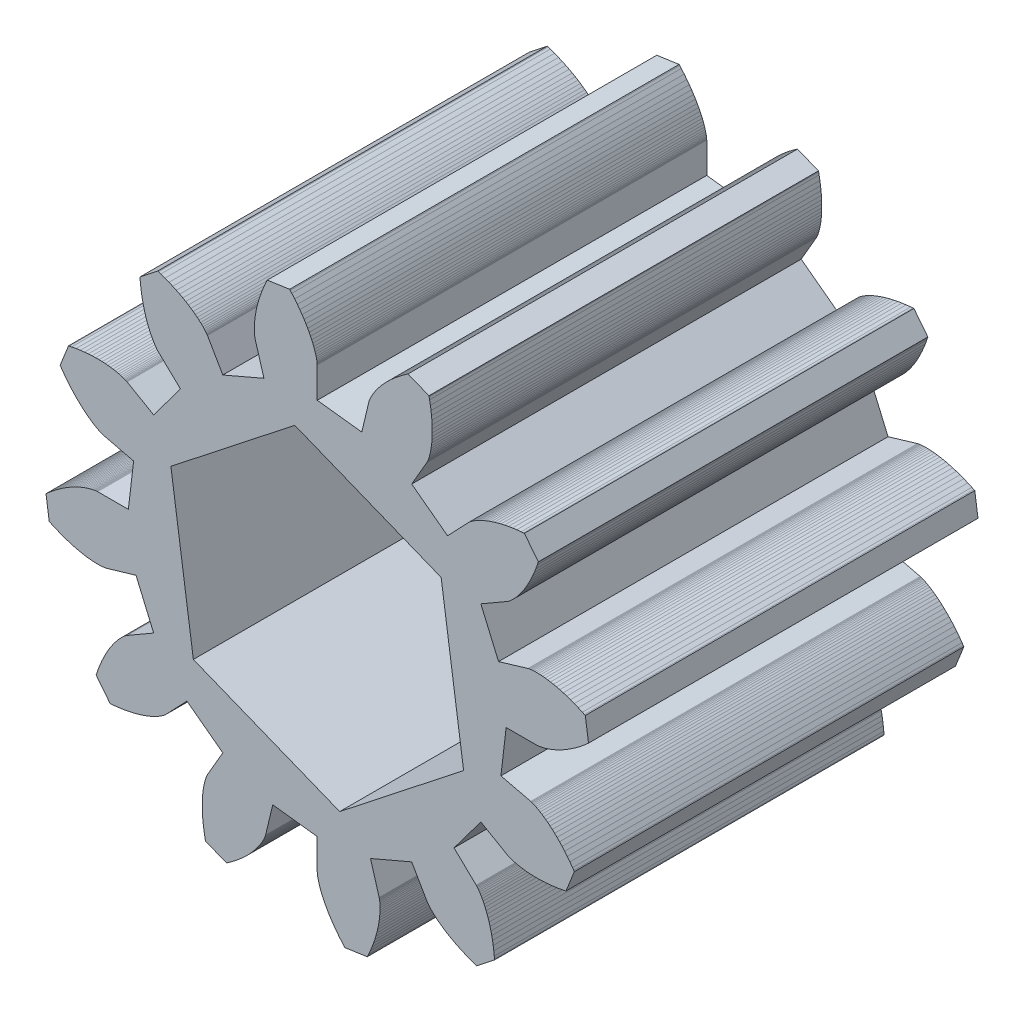
from build123d import *

# Parameters (mm, degrees)
EXTRUDE_2_DEPTH     = 5
CUT_EXTRUDE_1_DEPTH = 6


with BuildPart() as part:
    # Model → ﾎﾞｽ - 押し出し2 (new body)
    with BuildSketch(Plane.XY):
        Polygon((2.424979598, -4.222e-06), (2.819487016, -4.222e-06), (2.822108978, 8.7462e-05), (2.827108083, 0.000398469), (2.834472458, 0.001070503), (2.844181611, 0.002239522), (2.856212048, 0.004043437), (2.870533294, 0.006617481), (2.887107785, 0.010096584), (2.905893622, 0.014612545), (2.926841938, 0.02029636), (2.949899862, 0.027278337), (2.975007008, 0.03568572), (3.002097159, 0.045641409), (3.031101988, 0.057267741), (3.061942483, 0.070684521), (3.094539041, 0.086006313), (3.128804417, 0.103346504), (3.164641474, 0.122811276), (3.201971713, 0.144515903), (3.240674945, 0.168550426), (3.28065269, 0.195017919), (3.321792758, 0.224010967), (3.36398147, 0.255617752), (3.407100449, 0.289922735), (3.451033569, 0.32701359), (3.473258892, 0.346619993), (3.478840026, 0.351634113), (3.481641457, 0.354150934), (3.440698379, 0.641540019), (3.436883916, 0.643384276), (3.430129287, 0.646650076), (3.40330849, 0.659260423), (3.350757413, 0.682589263), (3.299767283, 0.703471908), (3.250424462, 0.722023522), (3.202819232, 0.738358883), (3.157035875, 0.752593787), (3.113156689, 0.764850032), (3.071246876, 0.775252205), (3.031397088, 0.783922058), (2.993650247, 0.790991304), (2.958069816, 0.796588254), (2.924708123, 0.800847778), (2.893609492, 0.80390177), (2.864816257, 0.805887125), (2.838359748, 0.806938769), (2.814269306, 0.807196629), (2.792567266, 0.806797652), (2.773267971, 0.805881803), (2.75638176, 0.804588056), (2.741911972, 0.803055405), (2.729856949, 0.801423854), (2.720208032, 0.799832424), (2.712949555, 0.798418155), (2.708062855, 0.797319091), (2.705520267, 0.796672301), (2.327446991, 0.683992664), (2.100105416, 1.21248071), (2.441756143, 1.409739129), (2.443981931, 1.411127997), (2.448155777, 1.413896895), (2.454197677, 1.418160824), (2.462021578, 1.42402775), (2.471538133, 1.431605395), (2.482653848, 1.440994999), (2.495268621, 1.452294796), (2.509279565, 1.465598744), (2.524579242, 1.480995418), (2.541056364, 1.498571548), (2.558596535, 1.518405742), (2.577079478, 1.540572673), (2.596384821, 1.565144109), (2.616385808, 1.592183092), (2.636953678, 1.621750906), (2.657958434, 1.653900532), (2.679262013, 1.688675948), (2.700738877, 1.726137687), (2.72223945, 1.76630389), (2.743627606, 1.809214204), (2.764759479, 1.854892929), (2.785492363, 1.903359658), (2.805681612, 1.954628288), (2.825184179, 2.008716183), (2.834628019, 2.036808707), (2.836954933, 2.043941444), (2.838112173, 2.047525185), (2.658959587, 2.275939939), (2.654734375, 2.275625296), (2.647254103, 2.275045642), (2.617726989, 2.272491125), (2.560565917, 2.266289323), (2.505982803, 2.258755277), (2.453994401, 2.250032755), (2.404621463, 2.240264695), (2.357878497, 2.229594955), (2.313775498, 2.218170248), (2.272306448, 2.2061305), (2.233489186, 2.193624814), (2.197293861, 2.180791394), (2.163710692, 2.167773573), (2.132718409, 2.154711243), (2.104288575, 2.141742192), (2.078388998, 2.129006261), (2.054978926, 2.11663608), (2.034013762, 2.104766886), (2.015444025, 2.093528445), (1.99921222, 2.083048459), (1.985256909, 2.073453293), (1.973511305, 2.064864663), (1.963903981, 2.057402435), (1.956357685, 2.051182494), (1.950789471, 2.046316218), (1.947114224, 2.042913229), (1.945240347, 2.041077017), (1.67299881, 1.755558806), (1.212332587, 2.100189676), (1.40975052, 2.441748255), (1.410984204, 2.444063663), (1.41321379, 2.44854883), (1.41631411, 2.455262523), (1.420156095, 2.464255487), (1.424608963, 2.475576153), (1.4295402, 2.489265809), (1.43481527, 2.505359023), (1.440297266, 2.523886012), (1.445847995, 2.544869985), (1.451331127, 2.568329549), (1.456603172, 2.594276772), (1.461527082, 2.622715252), (1.465960249, 2.653647415), (1.469762128, 2.687064354), (1.472791158, 2.722954714), (1.474906148, 2.761299531), (1.475967971, 2.802067711), (1.475836949, 2.845248962), (1.474373973, 2.890784204), (1.471440944, 2.938639669), (1.466902951, 2.988764599), (1.460624965, 3.041104481), (1.452474885, 3.095599017), (1.442320147, 3.1521917), (1.436453168, 3.181242596), (1.434901286, 3.18858304), (1.434112004, 3.192265355), (1.164754238, 3.300502144), (1.161252634, 3.298116733), (1.155052015, 3.29389266), (1.130734162, 3.276951053), (1.084283195, 3.243066571), (1.040731658, 3.209312432), (1.000022024, 3.175822105), (0.962100784, 3.142730089), (0.926907907, 3.110169228), (0.89438123, 3.078269169), (0.864443041, 3.047150968), (0.83703557, 3.016951588), (0.812064952, 2.987775117), (0.789450153, 2.959741855), (0.769102961, 2.932962426), (0.750929765, 2.907542224), (0.734834398, 2.883585362), (0.720713262, 2.861187899), (0.708462699, 2.840443271), (0.697972501, 2.821440812), (0.689130672, 2.804261649), (0.681821177, 2.788984569), (0.67592442, 2.775682236), (0.671319309, 2.764422642), (0.66788082, 2.755267805), (0.665481629, 2.74827284), (0.6639939, 2.743490117), (0.663284819, 2.740964192), (0.571318182, 2.357326029), (-2.274e-06, 2.424977651), (-2.274e-06, 2.819485069), (-9.3958e-05, 2.822107031), (-0.000404965, 2.827106136), (-0.001076999, 2.834470511), (-0.002246017, 2.844179664), (-0.004049933, 2.8562101), (-0.006623977, 2.870531346), (-0.01010308, 2.887105837), (-0.014619041, 2.905891674), (-0.020302856, 2.926839991), (-0.027284833, 2.949897915), (-0.035692216, 2.97500506), (-0.045647904, 3.002095212), (-0.057274237, 3.031100041), (-0.070691017, 3.061940535), (-0.086012809, 3.094537093), (-0.103353, 3.12880247), (-0.122817771, 3.164639527), (-0.144522399, 3.201969766), (-0.168556922, 3.240672998), (-0.195024415, 3.280650743), (-0.224017463, 3.32179081), (-0.255624248, 3.363979523), (-0.289929231, 3.407098502), (-0.327020086, 3.451031621), (-0.346626488, 3.473256944), (-0.351640609, 3.478838078), (-0.35415743, 3.48163951), (-0.641546515, 3.440696432), (-0.643390772, 3.436881969), (-0.646656571, 3.430127339), (-0.659277311, 3.403311431), (-0.682626512, 3.350769397), (-0.703528914, 3.299787363), (-0.722099645, 3.250451734), (-0.738453452, 3.202852837), (-0.752706095, 3.157075), (-0.764979342, 3.113200566), (-0.775397753, 3.071294787), (-0.784083047, 3.031448361), (-0.79116692, 2.993704263), (-0.796777656, 2.958126003), (-0.801050107, 2.924765964), (-0.804116149, 2.893668518), (-0.806112661, 2.864876055), (-0.807174556, 2.838419955), (-0.807441751, 2.814329614), (-0.807051183, 2.792627422), (-0.806142812, 2.773327773), (-0.804855609, 2.756441062), (-0.803328565, 2.741970681), (-0.801701685, 2.729915027), (-0.800113995, 2.720265494), (-0.798702537, 2.71300647), (-0.797605367, 2.708119344), (-0.796959563, 2.705576506), (-0.684053296, 2.327570848), (-1.212487206, 2.100103469), (-1.409745625, 2.441754195), (-1.411134493, 2.443979984), (-1.413903391, 2.448153829), (-1.41816732, 2.454195729), (-1.424034246, 2.46201963), (-1.431611891, 2.471536185), (-1.441001495, 2.4826519), (-1.452301292, 2.495266673), (-1.465605239, 2.509277618), (-1.481001914, 2.524577295), (-1.498578044, 2.541054416), (-1.518412238, 2.558594588), (-1.540579169, 2.57707753), (-1.565150605, 2.596382873), (-1.592189588, 2.61638386), (-1.621757402, 2.636951731), (-1.653907028, 2.657956487), (-1.688682443, 2.679260065), (-1.726144183, 2.700736929), (-1.766310386, 2.722237502), (-1.809220699, 2.743625659), (-1.854899425, 2.764757532), (-1.903366154, 2.785490416), (-1.954634784, 2.805679664), (-2.008722679, 2.825182232), (-2.036815203, 2.834626072), (-2.04394794, 2.836952986), (-2.047531681, 2.838110225), (-2.27591146, 2.658487982), (-2.275631791, 2.654732428), (-2.275052138, 2.647252155), (-2.272497621, 2.617725042), (-2.266295819, 2.56056397), (-2.258761773, 2.505980855), (-2.250039251, 2.453992454), (-2.240271191, 2.404619516), (-2.22960145, 2.35787655), (-2.218176744, 2.31377355), (-2.206136996, 2.2723045), (-2.19363131, 2.233487239), (-2.18079789, 2.197291914), (-2.167780069, 2.163708744), (-2.154717739, 2.132716461), (-2.141748688, 2.104286628), (-2.129012757, 2.078387051), (-2.116642576, 2.054976979), (-2.104773381, 2.034011815), (-2.09353494, 2.015442077), (-2.083054955, 1.999210273), (-2.073459788, 1.985254962), (-2.064871159, 1.973509357), (-2.05740893, 1.963902034), (-2.05118899, 1.956355738), (-2.046322713, 1.950787524), (-2.042919725, 1.947112276), (-2.041083513, 1.945238399), (-1.755565302, 1.672996863), (-2.100196172, 1.21233064), (-2.441754751, 1.409748572), (-2.444070159, 1.410982257), (-2.448555326, 1.413211843), (-2.455269018, 1.416312162), (-2.464261983, 1.420154147), (-2.475582649, 1.424607016), (-2.489272305, 1.429538252), (-2.505365519, 1.434813322), (-2.523892507, 1.440295319), (-2.54487648, 1.445846047), (-2.568336044, 1.451329179), (-2.594283268, 1.456601224), (-2.622721748, 1.461525134), (-2.653653911, 1.465958301), (-2.68707085, 1.46976018), (-2.722961209, 1.472789211), (-2.761306027, 1.474904201), (-2.802074207, 1.475966023), (-2.845255458, 1.475835001), (-2.890790699, 1.474372025), (-2.938646165, 1.471438997), (-2.988771095, 1.466901003), (-3.041110977, 1.460623017), (-3.095605512, 1.452472937), (-3.152198196, 1.4423182), (-3.181249092, 1.436451221), (-3.188589536, 1.434899338), (-3.192271851, 1.434110057), (-3.30050864, 1.16475229), (-3.298123228, 1.161250686), (-3.293899156, 1.155050067), (-3.276957549, 1.130732215), (-3.243073067, 1.084281247), (-3.209318928, 1.040729711), (-3.175828601, 1.000020076), (-3.142736585, 0.962098836), (-3.110175724, 0.92690596), (-3.078275665, 0.894379283), (-3.047157463, 0.864441094), (-3.016958084, 0.837033623), (-2.987781613, 0.812063005), (-2.959748351, 0.789448206), (-2.932968922, 0.769101013), (-2.90754872, 0.750927817), (-2.883591858, 0.734832451), (-2.861194395, 0.720711314), (-2.840449767, 0.708460751), (-2.821447308, 0.697970554), (-2.804268145, 0.689128725), (-2.788991064, 0.681819229), (-2.775688732, 0.675922472), (-2.764429138, 0.671317361), (-2.7552743, 0.667878872), (-2.748279336, 0.665479681), (-2.743496613, 0.663991952), (-2.740970688, 0.663282871), (-2.357332525, 0.571316235), (-2.424984147, -4.222e-06), (-2.819491565, -4.222e-06), (-2.822113527, -9.5906e-05), (-2.827112632, -0.000406912), (-2.834477007, -0.001078947), (-2.844186159, -0.002247965), (-2.856216596, -0.00405188), (-2.870537842, -0.006625925), (-2.887112333, -0.010105028), (-2.90589817, -0.014620989), (-2.926846486, -0.020304803), (-2.949904411, -0.02728678), (-2.975011556, -0.035694164), (-3.002101708, -0.045649852), (-3.031106537, -0.057276184), (-3.061947031, -0.070692964), (-3.094543589, -0.086014757), (-3.128808966, -0.103354947), (-3.164646022, -0.122819719), (-3.201976262, -0.144524347), (-3.240679494, -0.16855887), (-3.280657238, -0.195026363), (-3.321797306, -0.22401941), (-3.363986019, -0.255626195), (-3.407104998, -0.289931178), (-3.451038117, -0.327022033), (-3.47326344, -0.346628436), (-3.478844574, -0.351642557), (-3.481646006, -0.354159377), (-3.440702928, -0.641548462), (-3.436888464, -0.643392719), (-3.430133835, -0.646658519), (-3.403334113, -0.659313594), (-3.350659, -0.682361), (-3.299618, -0.703119), (-3.25023, -0.72155), (-3.202585, -0.737769), (-3.156767, -0.751892), (-3.112858, -0.764041), (-3.070922897, -0.774340745), (-3.031052, -0.782913), (-2.993288, -0.78989), (-2.957694, -0.7954), (-2.924322, -0.799578), (-2.893216, -0.802556), (-2.864418, -0.804471), (-2.837959, -0.805458), (-2.813868, -0.805657), (-2.792167, -0.805205), (-2.77287, -0.804242), (-2.755987, -0.802907), (-2.741521, -0.801339), (-2.72947, -0.799678), (-2.719825, -0.798063), (-2.71257, -0.796631), (-2.707686, -0.79552), (-2.705145, -0.794867), (-2.326638, -0.683653), (-2.100108237, -1.212489527), (-2.441758964, -1.409747946), (-2.443984752, -1.411136814), (-2.448158597, -1.413905712), (-2.454200497, -1.418169641), (-2.462024399, -1.424036567), (-2.471540953, -1.431614213), (-2.482656668, -1.441003816), (-2.495271441, -1.452303613), (-2.509282386, -1.465607561), (-2.524582063, -1.481004235), (-2.541059185, -1.498580365), (-2.558599356, -1.518414559), (-2.577082299, -1.54058149), (-2.596387641, -1.565152926), (-2.616388628, -1.592191909), (-2.636956499, -1.621759723), (-2.657961255, -1.653909349), (-2.679264834, -1.688684765), (-2.700741697, -1.726146504), (-2.722242271, -1.766312707), (-2.743630427, -1.809223021), (-2.7647623, -1.854901746), (-2.785495184, -1.903368475), (-2.805684432, -1.954637106), (-2.825187, -2.008725), (-2.834630846, -2.036817522), (-2.836957761, -2.043950259), (-2.838115, -2.047534), (-2.658964135, -2.275948382), (-2.654738923, -2.275633739), (-2.647258651, -2.275054085), (-2.617731538, -2.272499568), (-2.560570466, -2.266297766), (-2.505987351, -2.25876372), (-2.453998949, -2.250041198), (-2.404626012, -2.240273138), (-2.357883045, -2.229603398), (-2.313780046, -2.218178692), (-2.272310996, -2.206138943), (-2.233493735, -2.193633257), (-2.19729841, -2.180799837), (-2.16371524, -2.167782016), (-2.132722957, -2.154719687), (-2.104293124, -2.141750635), (-2.078393546, -2.129014705), (-2.054983475, -2.116644523), (-2.03401831, -2.104775329), (-2.015448573, -2.093536888), (-1.999216769, -2.083056902), (-1.985261458, -2.073461736), (-1.973515853, -2.064873107), (-1.96390853, -2.057410878), (-1.956362234, -2.051190937), (-1.95079402, -2.046324661), (-1.947118772, -2.042921672), (-1.945244895, -2.04108546), (-1.673003359, -1.755567249), (-1.212337136, -2.10019812), (-1.409755068, -2.441756699), (-1.410988753, -2.444072106), (-1.413218338, -2.448557273), (-1.416318658, -2.455270966), (-1.420160643, -2.46426393), (-1.424613512, -2.475584596), (-1.429544748, -2.489274252), (-1.434819818, -2.505367467), (-1.440301815, -2.523894455), (-1.445852543, -2.544878428), (-1.451335675, -2.568337992), (-1.45660772, -2.594285215), (-1.46153163, -2.622723695), (-1.465964797, -2.653655859), (-1.469766676, -2.687072797), (-1.472795707, -2.722963157), (-1.474910697, -2.761307975), (-1.475972519, -2.802076155), (-1.475841497, -2.845257406), (-1.474378521, -2.890792647), (-1.471445493, -2.938648113), (-1.466907499, -2.988773043), (-1.460629513, -3.041112924), (-1.452479433, -3.09560746), (-1.442324696, -3.152200143), (-1.436457717, -3.181251039), (-1.434905834, -3.188591484), (-1.434116552, -3.192273798), (-1.164758786, -3.300510587), (-1.161257182, -3.298125176), (-1.155056563, -3.293901104), (-1.130738711, -3.276959496), (-1.084287743, -3.243075015), (-1.040736206, -3.209320876), (-1.000026572, -3.175830549), (-0.962105332, -3.142738533), (-0.926912455, -3.110177671), (-0.894385778, -3.078277612), (-0.864447589, -3.047159411), (-0.837040119, -3.016960031), (-0.812069501, -2.987783561), (-0.789454701, -2.959750298), (-0.769107509, -2.932970869), (-0.750934313, -2.907550667), (-0.734838946, -2.883593806), (-0.72071781, -2.861196343), (-0.708467247, -2.840451714), (-0.69797705, -2.821449255), (-0.68913522, -2.804270092), (-0.681825725, -2.788993012), (-0.675928968, -2.77569068), (-0.671323857, -2.764431085), (-0.667885368, -2.755276248), (-0.665486177, -2.748281283), (-0.663998448, -2.74349856), (-0.663289367, -2.740972636), (-0.57132273, -2.357334472), (-2.274e-06, -2.424986094), (-2.274e-06, -2.819493512), (8.941e-05, -2.822115474), (0.000400416, -2.827114579), (0.001072451, -2.834478954), (0.002241469, -2.844188107), (0.004045385, -2.856218544), (0.006619429, -2.870539789), (0.010098532, -2.88711428), (0.014614493, -2.905900117), (0.020298307, -2.926848434), (0.027280284, -2.949906358), (0.035687668, -2.975013504), (0.045643356, -3.002103655), (0.057269688, -3.031108484), (0.070686468, -3.061948978), (0.086008261, -3.094545537), (0.103348451, -3.128810913), (0.122813223, -3.16464797), (0.144517851, -3.201978209), (0.168552374, -3.240681441), (0.195019867, -3.280659186), (0.224012915, -3.321799254), (0.255619699, -3.363987966), (0.289924683, -3.407106945), (0.327015537, -3.451040064), (0.34662194, -3.473265387), (0.351636061, -3.478846522), (0.354152882, -3.481647953), (0.641541966, -3.440704875), (0.643386223, -3.436890412), (0.646652023, -3.430135782), (0.65926237, -3.403314985), (0.682591211, -3.350763909), (0.703473856, -3.299773778), (0.722025469, -3.250430958), (0.73836083, -3.202825727), (0.751794452, -3.156800885), (0.763998444, -3.112907138), (0.77435071, -3.07098497), (0.78297311, -3.031124887), (0.789997409, -2.993369656), (0.795551991, -2.957782586), (0.79977179, -2.924415846), (0.802788752, -2.8933136), (0.804739824, -2.864518022), (0.805759967, -2.838060279), (0.805989144, -2.813969547), (0.805564328, -2.792267998), (0.8046255, -2.772969807), (0.80331165, -2.756085148), (0.801761772, -2.741617195), (0.800115868, -2.729564124), (0.798512951, -2.719917108), (0.79709004, -2.71266032), (0.795985159, -2.707774933), (0.795335342, -2.705233117), (0.683731504, -2.326840878), (1.212482657, -2.100111912), (1.409741077, -2.441762639), (1.411129945, -2.443988427), (1.413898842, -2.448162272), (1.418162772, -2.454204172), (1.424029698, -2.462028074), (1.431607343, -2.471544628), (1.440996947, -2.482660343), (1.452296744, -2.495275116), (1.465600691, -2.509286061), (1.480997366, -2.524585738), (1.498573496, -2.54106286), (1.518407689, -2.558603031), (1.540574621, -2.577085974), (1.565146057, -2.596391316), (1.59218504, -2.616392303), (1.621752854, -2.636960174), (1.65390248, -2.65796493), (1.688677895, -2.679268509), (1.726139635, -2.700745372), (1.766305837, -2.722245946), (1.809216151, -2.743634102), (1.854894876, -2.764765975), (1.903361605, -2.785498859), (1.954630236, -2.805688107), (2.00871813, -2.825190675), (2.036810654, -2.834634515), (2.043943391, -2.836961429), (2.047527133, -2.838118669), (2.275906912, -2.658496425), (2.275627243, -2.654740871), (2.275047589, -2.647260599), (2.272493072, -2.617733485), (2.26629127, -2.560572413), (2.258757224, -2.505989299), (2.250034703, -2.454000897), (2.240266643, -2.404627959), (2.229596902, -2.357884993), (2.218172196, -2.313781993), (2.206132448, -2.272312944), (2.193626762, -2.233495682), (2.180793342, -2.197300357), (2.167775521, -2.163717188), (2.154713191, -2.132724905), (2.14174414, -2.104295071), (2.129008209, -2.078395494), (2.116638027, -2.054985422), (2.104768833, -2.034020258), (2.093530392, -2.015450521), (2.083050406, -1.999218716), (2.07345524, -1.985263405), (2.064866611, -1.973517801), (2.057404382, -1.963910477), (2.051184441, -1.956364181), (2.046318165, -1.950795967), (2.042915176, -1.94712072), (2.041078964, -1.945246842), (1.755560754, -1.673005306), (2.100191624, -1.212339083), (2.441750203, -1.409757016), (2.444065611, -1.4109907), (2.448550778, -1.413220286), (2.45526447, -1.416320606), (2.464257434, -1.42016259), (2.4755781, -1.424615459), (2.489267757, -1.429546696), (2.505360971, -1.434821766), (2.523887959, -1.440303762), (2.544871932, -1.445854491), (2.568331496, -1.451337622), (2.594278719, -1.456609668), (2.622717199, -1.461533578), (2.653649363, -1.465966745), (2.687066302, -1.469768624), (2.722956661, -1.472797654), (2.761301479, -1.474912644), (2.802069659, -1.475974466), (2.84525091, -1.475843444), (2.890786151, -1.474380469), (2.938641617, -1.47144744), (2.988766547, -1.466909447), (3.041106428, -1.460631461), (3.095600964, -1.452481381), (3.152193647, -1.442326643), (3.181244543, -1.436459664), (3.188584988, -1.434907782), (3.192267302, -1.4341185), (3.300504091, -1.164760733), (3.29811868, -1.16125913), (3.293894608, -1.15505851), (3.276953, -1.130740658), (3.243068519, -1.084289691), (3.20931438, -1.040738154), (3.175824053, -1.00002852), (3.142732037, -0.96210728), (3.110171176, -0.926914403), (3.078271117, -0.894387726), (3.047152915, -0.864449537), (3.016953536, -0.837042066), (2.987777065, -0.812071448), (2.959743802, -0.789456649), (2.932964373, -0.769109456), (2.907544171, -0.75093626), (2.88358731, -0.734840894), (2.861189847, -0.720719758), (2.840445219, -0.708469195), (2.821442759, -0.697978997), (2.804263597, -0.689137168), (2.788986516, -0.681827673), (2.775684184, -0.675930916), (2.764424589, -0.671325804), (2.755269752, -0.667887315), (2.748274787, -0.665488124), (2.743492064, -0.664000396), (2.74096614, -0.663291315), (2.357327976, -0.571324678), align=None)
    extrude(amount=EXTRUDE_2_DEPTH)

    # ｽｹｯﾁ3 → ｶｯﾄ - 押し出し1 (cut, through all)
    with BuildSketch(Plane.XY.offset(5)):
        Polygon((0.288201519, -2.002984827), (1.878736503, -0.751902577), (1.590534984, 1.25108225), (-0.288201519, 2.002984827), (-1.878736503, 0.751902577), (-1.590534984, -1.25108225), align=None)
    extrude(amount=-CUT_EXTRUDE_1_DEPTH, mode=Mode.SUBTRACT)


solid = part.part
